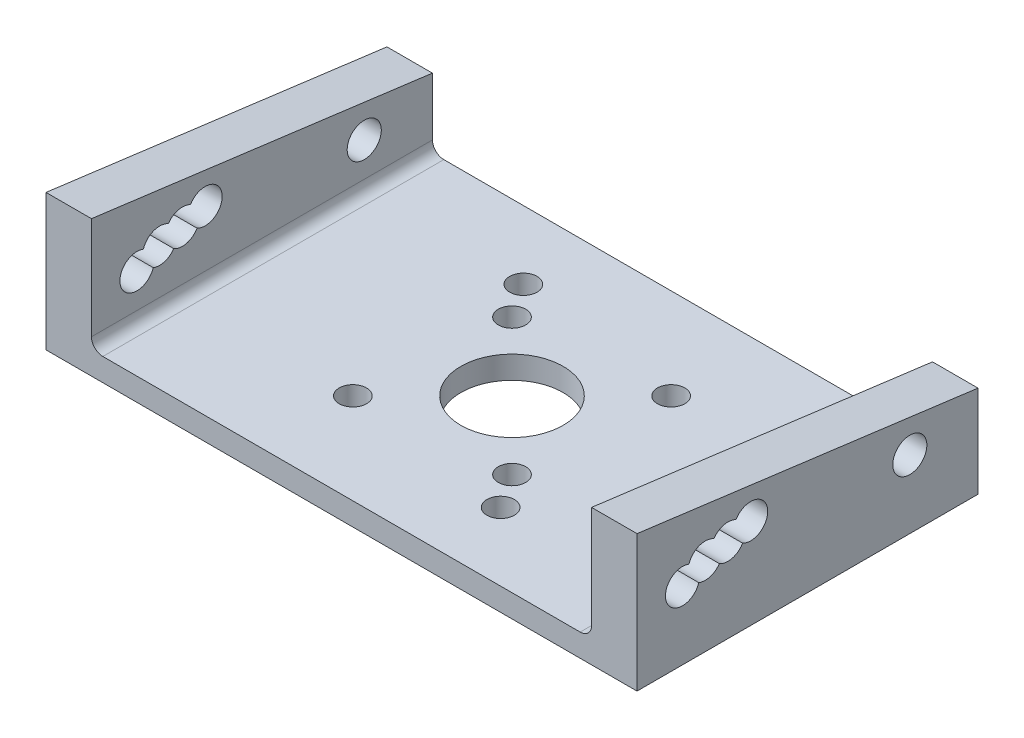
from build123d import *

# Parameters (mm, degrees)
ESBO_O1_W                = 52
ESBO_O1_H                = 30
ESBO_O1_R                = 4.5
ESBO_O1_R_2              = 1.205837633
RESSALTO_EXTRUS_O1_DEPTH = 2
ESBO_O2_R                = 1.5
RESSALTO_EXTRUS_O2_DEPTH = 4
FILETE3_R                = 1


with BuildPart() as part:
    # Esboço1 → Ressalto-extrusão1 (new body)
    with BuildSketch(Plane(origin=(0, 0, 0), x_dir=(1, 0, 0), z_dir=(0, 1, 0))):
        Rectangle(ESBO_O1_W, ESBO_O1_H)
        Circle(ESBO_O1_R, mode=Mode.SUBTRACT)
        with Locations((7, 7)):
            Circle(ESBO_O1_R_2, mode=Mode.SUBTRACT)
        with Locations((-6, 6)):
            Circle(ESBO_O1_R_2, mode=Mode.SUBTRACT)
        with Locations((-8, 9)):
            Circle(ESBO_O1_R_2, mode=Mode.SUBTRACT)
        with Locations((-7, -7)):
            Circle(ESBO_O1_R_2, mode=Mode.SUBTRACT)
        with Locations((6, -6)):
            Circle(ESBO_O1_R_2, mode=Mode.SUBTRACT)
        with Locations((8, -9)):
            Circle(ESBO_O1_R_2, mode=Mode.SUBTRACT)
    extrude(amount=RESSALTO_EXTRUS_O1_DEPTH)

    # Esboço2 → Ressalto-extrusão2 (add)
    with BuildSketch(Plane.ZY.offset(26)):
        Polygon((15, 2), (15, 12), (-15, 8.089445099), (-15, 2), align=None)
        with Locations((-9, 6)):
            Circle(ESBO_O2_R, mode=Mode.SUBTRACT)
        with BuildLine():
            ThreePointArc((8.240400933, 8.233448591), (9.539925295, 8.339457279), (10.431505763, 7.388097368))
            ThreePointArc((10.431505763, 7.388097368), (11.835840488, 7.245540316), (12.5, 6))
            ThreePointArc((12.5, 6), (11.226651005, 4.51722243), (9.568494237, 5.551902632))
            ThreePointArc((9.568494237, 5.551902632), (8.567535869, 5.503694052), (7.759599067, 6.096551409))
            ThreePointArc((7.759599067, 6.096551409), (6.624037685, 5.937880054), (5.708151293, 6.62768319))
            ThreePointArc((5.708151293, 6.62768319), (3.55555397, 8.354444888), (6.291848707, 8.71231681))
            ThreePointArc((6.291848707, 8.71231681), (7.357982, 8.84665675), (8.240400933, 8.233448591))
        make_face(mode=Mode.SUBTRACT)
    ressalto_extrus_o2 = extrude(amount=-RESSALTO_EXTRUS_O2_DEPTH)

    # Espelhar1: Ressalto-extrusão2 across plane
    add(ressalto_extrus_o2.mirror(Plane(origin=(0, 0, 0), x_dir=(0, 0, 1), z_dir=(1, 0, 0))))

    # Filete3
    filete3_edges = [part.edges().sort_by_distance(p)[0] for p in [
        (22, 2, 0),
        (-22, 2, 0),
    ]]
    fillet(filete3_edges, radius=FILETE3_R)


solid = part.part
